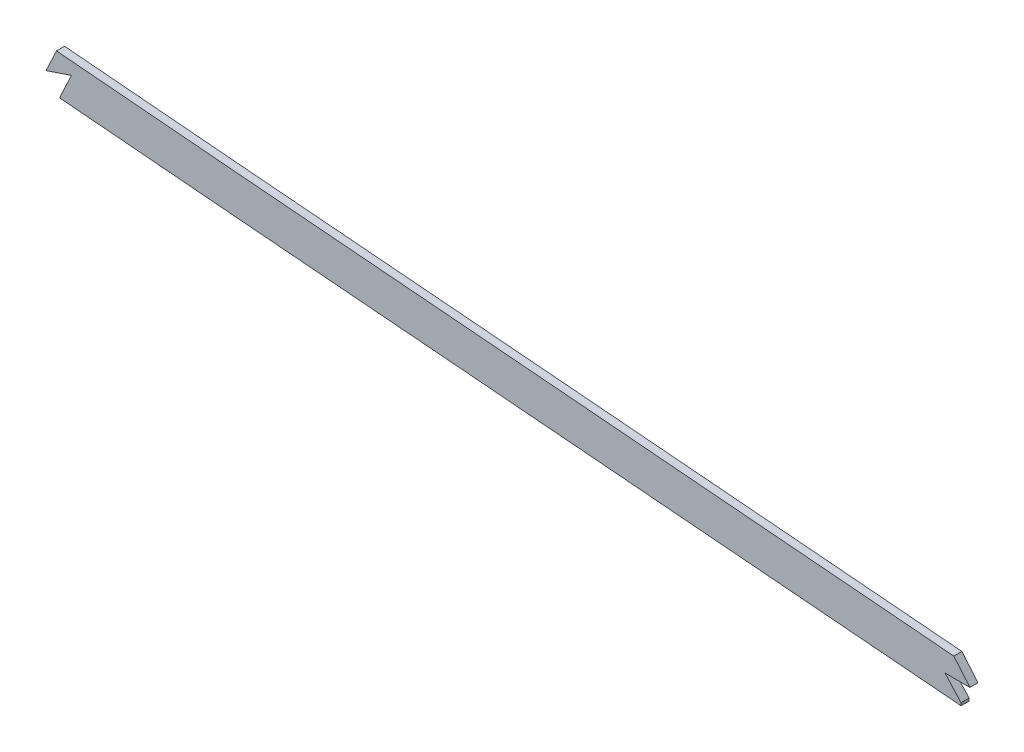
from build123d import *

# Parameters (mm, degrees)
BOSS_EXTRUDE1_DEPTH = 1.5875
FILLET1_R           = 2.54
CUT_EXTRUDE1_DEPTH  = 7.62


with BuildPart() as part:
    # Sketch2 → Boss-Extrude1 (new body, symmetric)
    with BuildSketch(Plane.XY):
        with BuildLine():
            add(Edge.make_bspline(
                [(825.5, 263.72872798), (833.004293944, 262.763036085), (840.535916247, 261.846014478), (848.126574562, 260.964164828), (892.90639318, 255.945629274), (937.686211733, 251.779150949), (973.452075064, 248.227669425), (1071.946672141, 239.051054038), (1170.441269319, 229.731506738), (1231.791940344, 224.503945813), (1324.899336146, 216.790627817), (1418.006730935, 209.040117978), (1449.742935921, 206.361809936), (1636.928606778, 190.521130342), (1824.114277635, 175.409157235), (1979.966947376, 164.299650253), (2156.268639429, 150.414433314), (2332.570330468, 133.857216402), (2354.212983157, 131.78508222), (2394.341467798, 127.847039259), (2434.469952439, 123.717187755), (2453.57670361, 121.704562273), (2472.669581058, 119.647220503), (2491.74, 117.547195763)],
                knots=[78.681340958, 78.681340958, 78.681340958, 78.681340958, 78.681340958, 78.681340958, 82.46579272, 82.46579272, 82.46579272, 100.7932901, 100.7932901, 100.7932901, 131.0989539, 131.0989539, 131.0989539, 146.7691983, 146.7691983, 146.7691983, 223.5339586, 223.5339586, 223.5339586, 233.9431167, 233.9431167, 233.9431167, 243.40815085, 243.40815085, 243.40815085, 243.40815085, 243.40815085, 243.40815085], degree=5))
            Line((825.5, 263.72872798), (825.5, 248.364439806))
            add(Edge.make_bspline(
                [(825.5, 248.364439806), (827.20768691, 248.14708351), (833.784664511, 247.321927102), (845.28106727, 245.953419483), (860.086531547, 244.295598067), (879.830703434, 242.186646028), (904.369967092, 239.698279806), (933.571022669, 236.832150625), (962.642718041, 234.023667741), (991.762593943, 231.241975908), (1021.072010315, 228.475862291), (1060.376437315, 224.796956681), (1109.513015577, 220.184378862), (1168.511190361, 214.817071985), (1227.500129793, 209.662054042), (1306.133167947, 203.021178328), (1404.361477105, 194.920725932), (1522.239851071, 184.918066624), (1640.182856491, 175.167007786), (1758.165352567, 165.757639485), (1876.155384769, 156.590937079), (1994.08749188, 147.453250142), (2092.268692061, 139.624216053), (2170.748029042, 133.079656729), (2219.771730977, 128.842227836), (2258.983988247, 125.347211495), (2288.379457536, 122.670854497), (2317.812243116, 119.931729386), (2347.551509172, 117.100365283), (2377.159899727, 114.21011853), (2406.469653851, 111.26896801), (2435.81832606, 108.240091266), (2464.242715806, 105.222889554), (2482.876892709, 103.192325927), (2491.74, 102.214848055)],
                knots=[78.875303138, 78.875303138, 78.875303138, 78.875303138, 79.386176103, 80.841530691, 82.29688528, 83.752239868, 86.662949044, 89.57365822, 92.484367397, 95.395076573, 98.305785749, 101.216494926, 107.037913278, 112.859331631, 118.680749984, 124.502168336, 136.145005042, 147.787841747, 159.430678452, 171.073515158, 182.716351863, 194.359188568, 206.002025273, 211.823443626, 217.644861979, 220.555571155, 223.466280331, 226.376989508, 229.287698684, 232.19840786, 235.109117037, 238.019826213, 240.930535389, 243.57402126, 243.57402126, 243.57402126, 243.57402126], degree=3))
            Line((2491.74, 102.214848055), (2491.74, 117.547195763))
        make_face()
    extrude(amount=BOSS_EXTRUDE1_DEPTH, both=True)

    # Fillet1
    fillet1_edges = [part.edges().sort_by_distance(p)[0] for p in [
        (2491.74, 102.214848055, -0.79375),
        (2491.74, 117.547195763, -0.79375),
        (825.5, 248.364439806, -0.79375),
        (825.5, 263.72872798, 0.79375),
    ]]
    fillet(fillet1_edges, radius=FILLET1_R)

    # Sketch3 → Cut-Extrude1 (cut)
    with BuildSketch(Plane.XY.offset(1.5875)):
        Polygon((1201.641901464, 227.227804562), (1201.641901464, 234.542162162), (821.218059657, 281.929544487), (821.218059657, 218.449722533), (1203.044971141, 207.573021892), (1203.044971141, 212.261982037), (1207.495802024, 221.814984909), (1197.508571749, 218.449722533), align=None)
        Polygon((1554.781712943, 197.53701635), (1561.124210439, 190.02917074), (1551.311808982, 190.02917074), (1557.611128436, 183.063577113), (1557.611128436, 178.064185516), (2509.688563149, 67.607566775), (2509.688563149, 142.671449404), (1554.781712943, 201.416206561), align=None)
    extrude(amount=-CUT_EXTRUDE1_DEPTH, mode=Mode.SUBTRACT)


solid = part.part
